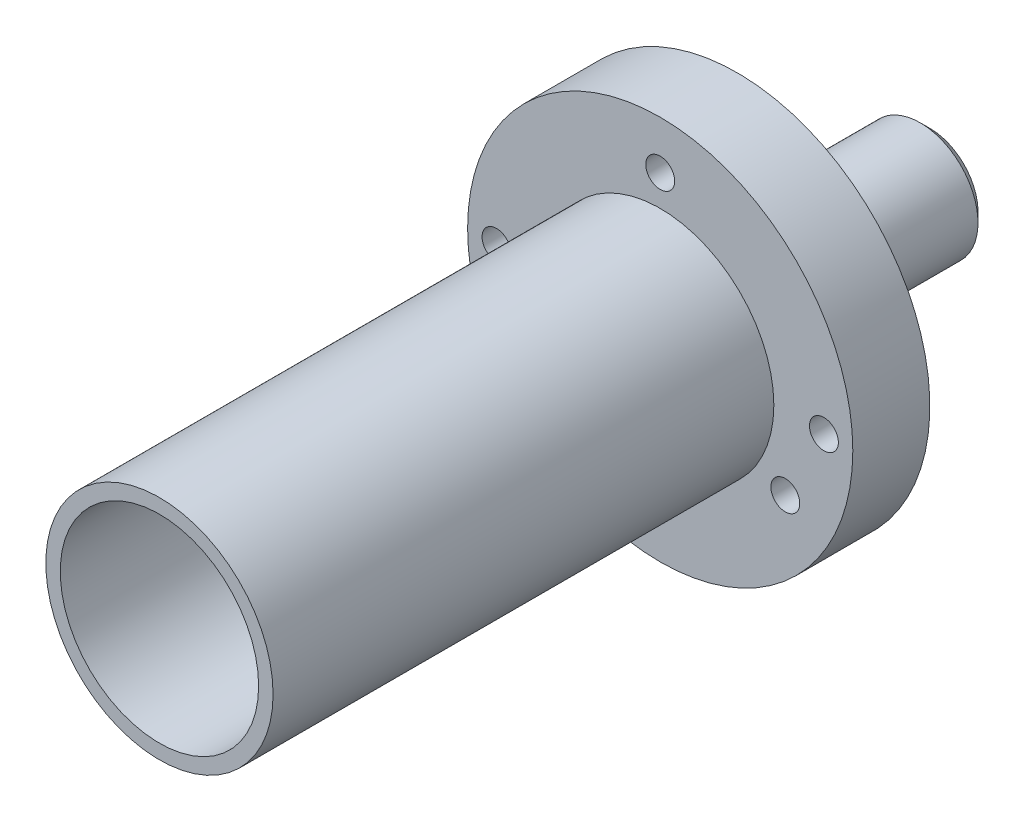
from build123d import *

# Parameters (mm, degrees)
SKETCH1_R           = 10
SKETCH1_R_2         = 5.15
BOSS_EXTRUDE1_DEPTH = 2
SKETCH3_R           = 3
BOSS_EXTRUDE2_DEPTH = 12
SKETCH4_R           = 10
SKETCH4_R_2         = 3
BOSS_EXTRUDE3_DEPTH = 2
CHAMFER2_SIZE       = 1
CHAMFER4_SIZE       = 0.5
CUT_EXTRUDE1_REACH  = 6
SKETCH5_R           = 0.75
SKETCH6_R           = 5.9
SKETCH6_R_2         = 5.15
BOSS_EXTRUDE4_DEPTH = 26
CUT_EXTRUDE2_REACH  = 32
SKETCH7_R           = 0.75


with BuildPart() as part:
    # Sketch1 → Boss-Extrude1 (new body)
    with BuildSketch(Plane.XY):
        Circle(SKETCH1_R)
        Circle(SKETCH1_R_2, mode=Mode.SUBTRACT)
    extrude(amount=BOSS_EXTRUDE1_DEPTH)



with BuildPart() as body_2:
    # Sketch3 → Boss-Extrude2 (new body)
    with BuildSketch(Plane(origin=(0, 0, 0), x_dir=(-1, 0, 0), z_dir=(0, 0, -1))):
        Circle(SKETCH3_R)
    extrude(amount=BOSS_EXTRUDE2_DEPTH)


with BuildPart() as part_1:
    add(part.part)

    add(body_2.part)  # Boss-Extrude3 merges body 2
    # Sketch4 → Boss-Extrude3 (add)
    with BuildSketch(Plane(origin=(0, 0, 0), x_dir=(-1, 0, 0), z_dir=(0, 0, -1))):
        Circle(SKETCH4_R)
        Circle(SKETCH4_R_2, mode=Mode.SUBTRACT)
    extrude(amount=BOSS_EXTRUDE3_DEPTH)

    # Chamfer2
    chamfer2_edges = [part_1.edges().sort_by_distance(p)[0] for p in [
        (3, 0, -2),
    ]]
    chamfer(chamfer2_edges, length=CHAMFER2_SIZE)

    # Chamfer4
    chamfer4_edges = [part_1.edges().sort_by_distance(p)[0] for p in [
        (3, 0, -12),
    ]]
    chamfer(chamfer4_edges, length=CHAMFER4_SIZE)

    # Sketch5 → Cut-Extrude1 (cut, up to next)
    with BuildSketch(Plane(origin=(0, 0, -2), x_dir=(-1, 0, 0), z_dir=(0, 0, -1)), mode=Mode.PRIVATE) as cut_extrude1_sk1:
        with Locations((-8.5, 0)):
            Circle(SKETCH5_R)
    cut_extrude1_tool1 = extrude(cut_extrude1_sk1.sketch, amount=-CUT_EXTRUDE1_REACH, mode=Mode.PRIVATE) & part_1.part
    add(cut_extrude1_tool1.solids().sort_by_distance((8.5, 0, -2))[0], mode=Mode.SUBTRACT)
    # Sketch5 → Cut-Extrude1 (cut, up to next)
    with BuildSketch(Plane(origin=(0, 0, -2), x_dir=(-1, 0, 0), z_dir=(0, 0, -1)), mode=Mode.PRIVATE) as cut_extrude1_sk2:
        with Locations((8.5, 0)):
            Circle(SKETCH5_R)
    cut_extrude1_tool2 = extrude(cut_extrude1_sk2.sketch, amount=-CUT_EXTRUDE1_REACH, mode=Mode.PRIVATE) & part_1.part
    add(cut_extrude1_tool2.solids().sort_by_distance((-8.5, 0, -2))[0], mode=Mode.SUBTRACT)

    # Sketch6 → Boss-Extrude4 (add)
    with BuildSketch(Plane.XY.offset(2)):
        Circle(SKETCH6_R)
        Circle(SKETCH6_R_2, mode=Mode.SUBTRACT)
    extrude(amount=BOSS_EXTRUDE4_DEPTH)

    # Sketch7 → Cut-Extrude2 (cut, up to next)
    with BuildSketch(Plane(origin=(0, 0, -2), x_dir=(-1, 0, 0), z_dir=(0, 0, -1)), mode=Mode.PRIVATE) as cut_extrude2_sk1:
        with Locations((0, 7.5)):
            Circle(SKETCH7_R)
    cut_extrude2_tool1 = extrude(cut_extrude2_sk1.sketch, amount=-CUT_EXTRUDE2_REACH, mode=Mode.PRIVATE) & part_1.part
    add(cut_extrude2_tool1.solids().sort_by_distance((0, 7.5, -2))[0], mode=Mode.SUBTRACT)
    # Sketch7 → Cut-Extrude2 (cut, up to next)
    with BuildSketch(Plane(origin=(0, 0, -2), x_dir=(-1, 0, 0), z_dir=(0, 0, -1)), mode=Mode.PRIVATE) as cut_extrude2_sk2:
        with Locations((6.495190528, -3.75)):
            Circle(SKETCH7_R)
    cut_extrude2_tool2 = extrude(cut_extrude2_sk2.sketch, amount=-CUT_EXTRUDE2_REACH, mode=Mode.PRIVATE) & part_1.part
    add(cut_extrude2_tool2.solids().sort_by_distance((-6.495191, -3.75, -2))[0], mode=Mode.SUBTRACT)
    # Sketch7 → Cut-Extrude2 (cut, up to next)
    with BuildSketch(Plane(origin=(0, 0, -2), x_dir=(-1, 0, 0), z_dir=(0, 0, -1)), mode=Mode.PRIVATE) as cut_extrude2_sk3:
        with Locations((-6.495190528, -3.75)):
            Circle(SKETCH7_R)
    cut_extrude2_tool3 = extrude(cut_extrude2_sk3.sketch, amount=-CUT_EXTRUDE2_REACH, mode=Mode.PRIVATE) & part_1.part
    add(cut_extrude2_tool3.solids().sort_by_distance((6.495191, -3.75, -2))[0], mode=Mode.SUBTRACT)


solid = part_1.part
